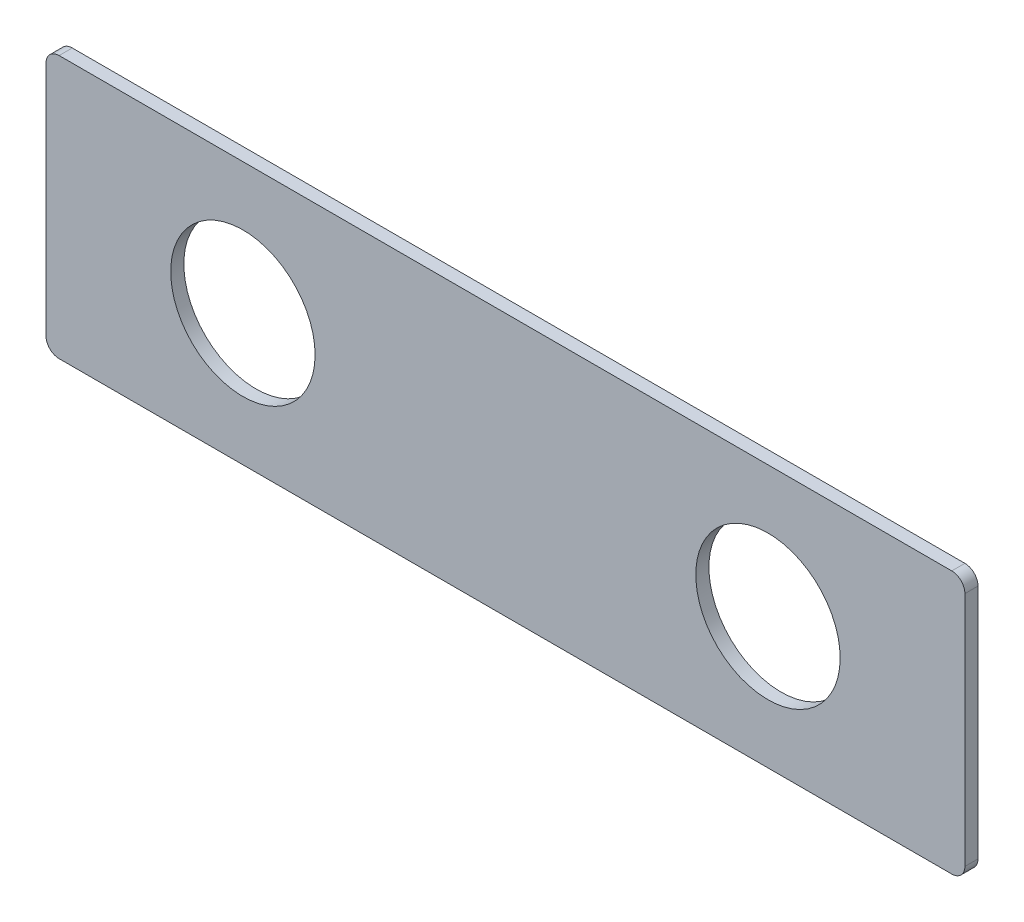
from build123d import *

# Parameters (mm, degrees)
SKETCH3_R      = 5.5
EXTRUDE2_DEPTH = 0.5


with BuildPart() as part:
    # Sketch3 → Extrude2 (new body, symmetric)
    with BuildSketch(Plane.XY):
        with BuildLine():
            Line((34, 0), (-34, 0))
            ThreePointArc((-34, 0), (-34.707106781, 0.292893219), (-35, 1))
            Line((-35, 1), (-35, 19))
            ThreePointArc((-35, 19), (-34.707106781, 19.707106781), (-34, 20))
            Line((-34, 20), (34, 20))
            ThreePointArc((34, 20), (34.707106781, 19.707106781), (35, 19))
            Line((35, 19), (35, 1))
            ThreePointArc((35, 1), (34.707106781, 0.292893219), (34, 0))
        make_face()
        with Locations((-20, 10)):
            Circle(SKETCH3_R, mode=Mode.SUBTRACT)
        with Locations((20, 10)):
            Circle(SKETCH3_R, mode=Mode.SUBTRACT)
    extrude(amount=EXTRUDE2_DEPTH, both=True)


solid = part.part
